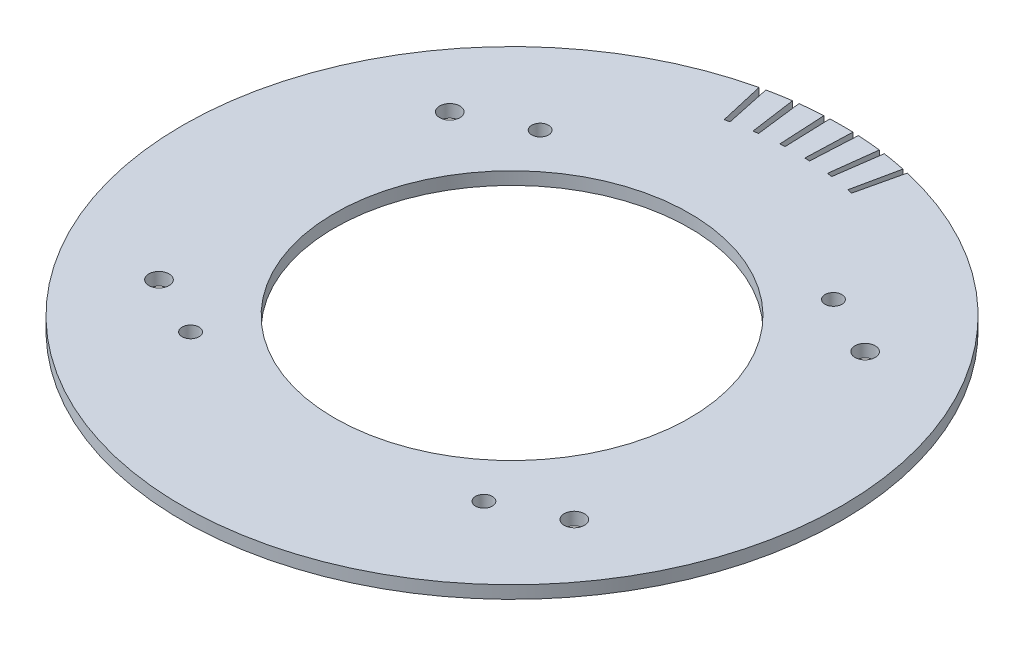
from build123d import *

# Parameters (mm, degrees)
F_98MM_6ID_CENTERING_RING_SKETCH_7_R = 53.34
CENTERING_RING_EXTRUDE_DEPTH         = 1.905
CENTERING_RING_EXTRUDE_DEPTH_BACK    = 1.905
CUT_EXTRUDE3_DEPTH                   = 4.81
CIRPATTERN1_COUNT                    = 6
CIRPATTERN1_ANGLE                    = 25
SKETCH5_R                            = 3.048
SKETCH5_R_2                          = 2.54
CUT_EXTRUDE4_DEPTH                   = 3.81


with BuildPart() as part:
    # 98mm - 6ID centering ring sketch_7 → Centering Ring Extrude (new body, two sides)
    with BuildSketch(Plane(origin=(0, 0, 0), x_dir=(1, 0, 0), z_dir=(0, 1, 0))) as centering_ring_extrude_sk:
        with BuildLine():
            Line((56.425744124, 3.175), (99.009105516, 3.175))
            ThreePointArc((99.009105516, 3.175), (70.045997744, 70.045997744), (3.175, 99.009105516))
            Line((3.175, 99.009105516), (3.175, 56.425744124))
            ThreePointArc((3.175, 56.425744124), (0, 56.515), (-3.175, 56.425744124))
            Line((-3.175, 56.425744124), (-3.175, 99.009105516))
            ThreePointArc((-3.175, 99.009105516), (-70.045997744, 70.045997744), (-99.009105516, 3.175))
            Line((-99.009105516, 3.175), (-56.425744124, 3.175))
            ThreePointArc((-56.425744124, 3.175), (-56.515, 0), (-56.425744124, -3.175))
            Line((-56.425744124, -3.175), (-99.009105516, -3.175))
            ThreePointArc((-99.009105516, -3.175), (-70.045997744, -70.045997744), (-3.175, -99.009105516))
            Line((-3.175, -99.009105516), (-3.175, -56.425744124))
            ThreePointArc((-3.175, -56.425744124), (0, -56.515), (3.175, -56.425744124))
            Line((3.175, -56.425744124), (3.175, -99.009105516))
            ThreePointArc((3.175, -99.009105516), (70.045997744, -70.045997744), (99.009105516, -3.175))
            Line((99.009105516, -3.175), (56.425744124, -3.175))
            ThreePointArc((56.425744124, -3.175), (56.515, 0), (56.425744124, 3.175))
        make_face()
        Circle(F_98MM_6ID_CENTERING_RING_SKETCH_7_R, mode=Mode.SUBTRACT)
        with BuildLine():
            ThreePointArc((99.06, 0), (99.047275562, 1.587703943), (99.009105516, 3.175))
            Line((99.009105516, 3.175), (56.425744124, 3.175))
            ThreePointArc((56.425744124, 3.175), (56.515, 0), (56.425744124, -3.175))
            Line((56.425744124, -3.175), (99.009105516, -3.175))
            ThreePointArc((99.009105516, -3.175), (99.047275562, -1.587703943), (99.06, 0))
        make_face()
        with BuildLine():
            Line((3.175, 56.425744124), (3.175, 99.009105516))
            ThreePointArc((3.175, 99.009105516), (0, 99.06), (-3.175, 99.009105516))
            Line((-3.175, 99.009105516), (-3.175, 56.425744124))
            ThreePointArc((-3.175, 56.425744124), (0, 56.515), (3.175, 56.425744124))
        make_face()
        with BuildLine():
            Line((-56.425744124, 3.175), (-99.009105516, 3.175))
            ThreePointArc((-99.009105516, 3.175), (-99.06, 0), (-99.009105516, -3.175))
            Line((-99.009105516, -3.175), (-56.425744124, -3.175))
            ThreePointArc((-56.425744124, -3.175), (-56.515, 0), (-56.425744124, 3.175))
        make_face()
        with BuildLine():
            ThreePointArc((-3.175, -99.009105516), (0, -99.06), (3.175, -99.009105516))
            Line((3.175, -99.009105516), (3.175, -56.425744124))
            ThreePointArc((3.175, -56.425744124), (0, -56.515), (-3.175, -56.425744124))
            Line((-3.175, -56.425744124), (-3.175, -99.009105516))
        make_face()
    extrude(amount=CENTERING_RING_EXTRUDE_DEPTH)
    extrude(centering_ring_extrude_sk.sketch, amount=-CENTERING_RING_EXTRUDE_DEPTH_BACK)

    # Sketch3 → Cut-Extrude3 (cut, through all)
    with BuildSketch(Plane(origin=(0, 1.905, 0), x_dir=(1, 0, 0), z_dir=(0, 1, 0))):
        with BuildLine():
            Line((-22.283651443, 96.521098618), (-19.141085214, 82.909148813))
            ThreePointArc((-19.141085214, 82.909148813), (-18.41684675, 83.073027246), (-17.691205772, 83.230579346))
            Line((-17.691205772, 83.230579346), (-20.595732092, 96.895301329))
            ThreePointArc((-20.595732092, 96.895301329), (-21.440508157, 96.711882465), (-22.283651443, 96.521098618))
        make_face()
    cut_extrude3 = extrude(amount=-CUT_EXTRUDE3_DEPTH, mode=Mode.SUBTRACT)

    # CirPattern1: Cut-Extrude3 ×6 about axis
    cirpattern1_axis = Axis((0, 0, 0), (0, -1, 0))
    for i in range(1, CIRPATTERN1_COUNT):
        add(cut_extrude3.rotate(cirpattern1_axis, i * CIRPATTERN1_ANGLE / (CIRPATTERN1_COUNT - 1)), mode=Mode.SUBTRACT)

    # Sketch5 → Cut-Extrude4 (cut)
    with BuildSketch(Plane.XZ.offset(1.905)):
        with Locations((-62.419385775, 43.70652445)):
            Circle(SKETCH5_R)
        with Locations((-44.082374272, 52.535327909)):
            Circle(SKETCH5_R_2)
        with Locations((44.082374272, 52.535327909)):
            Circle(SKETCH5_R_2)
        with Locations((62.419385775, 43.70652445)):
            Circle(SKETCH5_R)
        with Locations((62.419385775, -43.70652445)):
            Circle(SKETCH5_R)
        with Locations((44.082374272, -52.535327909)):
            Circle(SKETCH5_R_2)
        with Locations((-44.082374272, -52.535327909)):
            Circle(SKETCH5_R_2)
        with Locations((-62.419385775, -43.70652445)):
            Circle(SKETCH5_R)
    extrude(amount=-CUT_EXTRUDE4_DEPTH, mode=Mode.SUBTRACT)


solid = part.part
